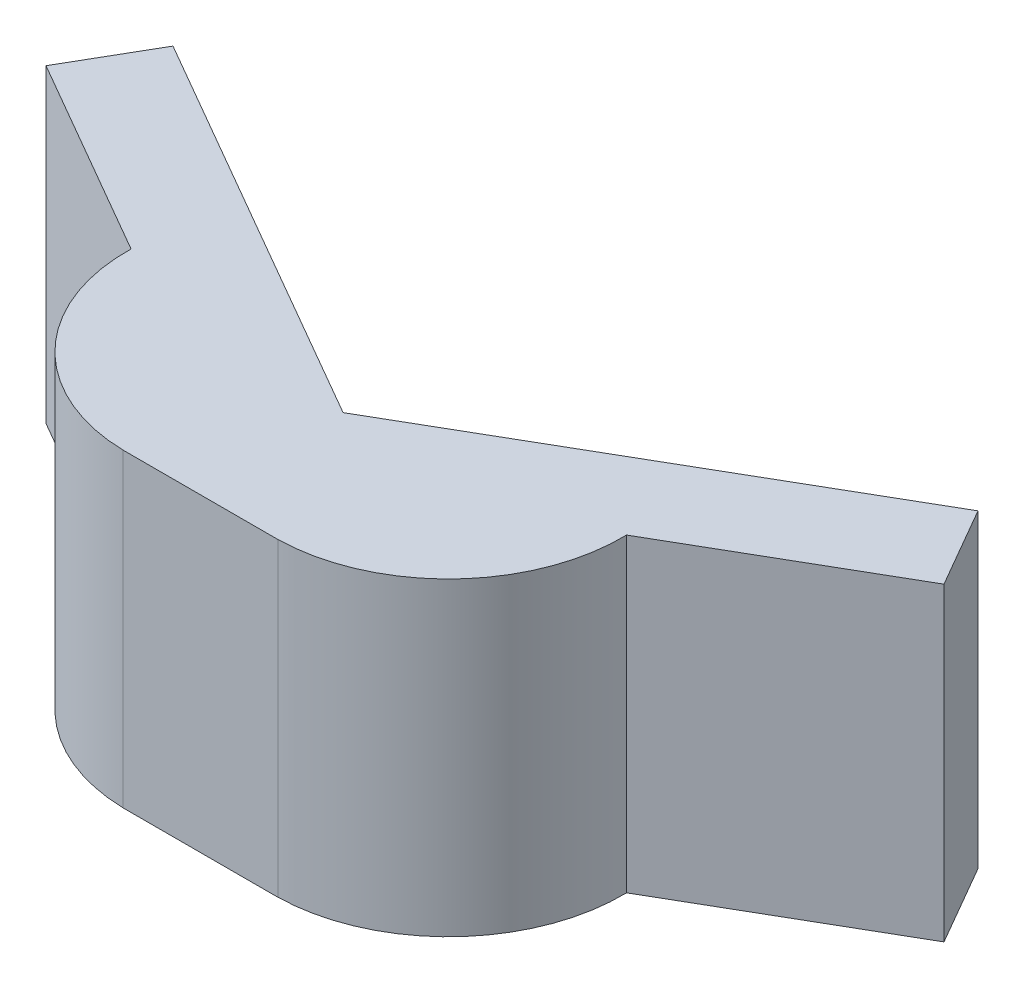
from build123d import *

# Parameters (mm, degrees)
BOSS_EXTRUDE1_DEPTH = 12.7


with BuildPart() as part:
    # Sketch1 → Boss-Extrude1 (new body)
    with BuildSketch(Plane(origin=(0, 0, 0), x_dir=(1, 0, 0), z_dir=(0, 1, 0))):
        with BuildLine():
            Line((0, 0), (16.497783942, 9.525))
            Line((16.497783942, 9.525), (18.402783942, 6.225443212))
            Line((18.402783942, 6.225443212), (10.153891971, 1.462943212))
            ThreePointArc((10.153891971, 1.462943212), (8.176843255, -3.633682641), (3.175, -5.839556788))
            Line((3.175, -5.839556788), (-3.175, -5.839556788))
            ThreePointArc((-3.175, -5.839556788), (-8.176843255, -3.633682641), (-10.153891971, 1.462943212))
            Line((-10.153891971, 1.462943212), (-18.402783942, 6.225443212))
            Line((-18.402783942, 6.225443212), (-16.497783942, 9.525))
            Line((-16.497783942, 9.525), (0, 0))
        make_face()
    extrude(amount=BOSS_EXTRUDE1_DEPTH)


solid = part.part
